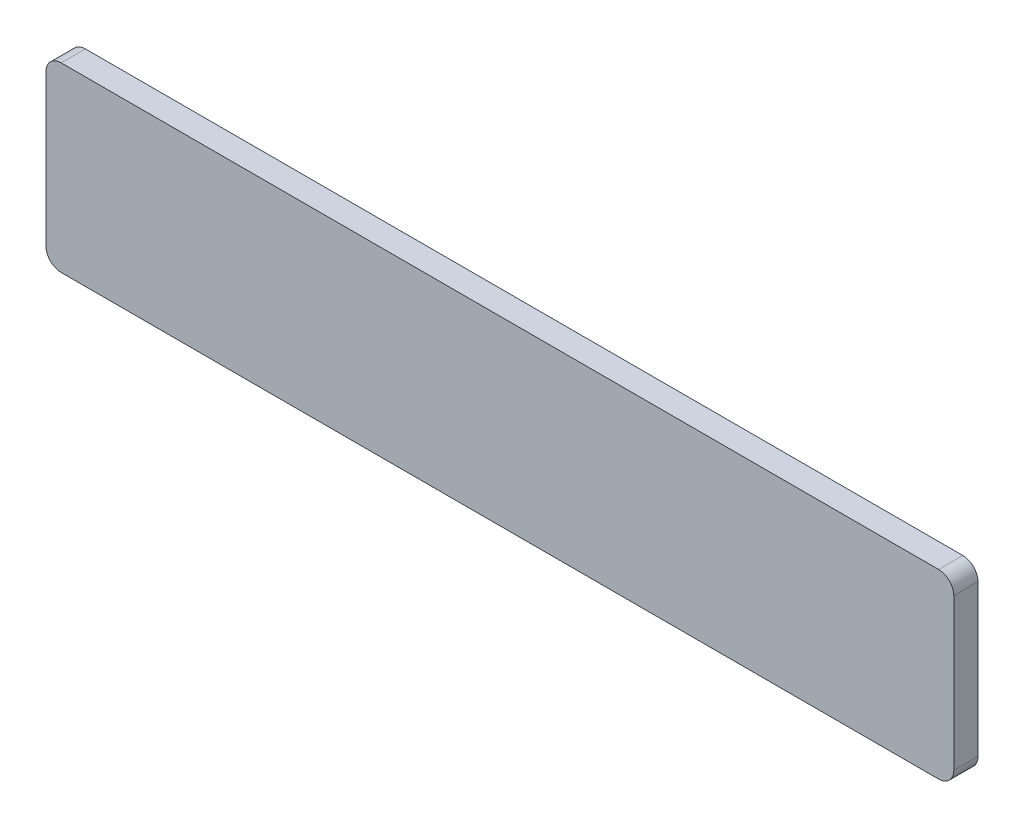
from build123d import *

# Parameters (mm, degrees)
BOSS_EXTRUDE2_DEPTH = 0.8


with BuildPart() as part:
    # Sketch2 → Boss-Extrude2 (new body)
    with BuildSketch(Plane.XY):
        with BuildLine():
            Line((0.5, 0), (29.5, 0))
            ThreePointArc((29.5, 0), (29.853553391, 0.146446609), (30, 0.5))
            Line((30, 0.5), (30, 5.5))
            ThreePointArc((30, 5.5), (29.853553391, 5.853553391), (29.5, 6))
            Line((29.5, 6), (0.5, 6))
            ThreePointArc((0.5, 6), (0.146446609, 5.853553391), (0, 5.5))
            Line((0, 5.5), (0, 0.5))
            ThreePointArc((0, 0.5), (0.146446609, 0.146446609), (0.5, 0))
        make_face()
    extrude(amount=BOSS_EXTRUDE2_DEPTH)


solid = part.part
